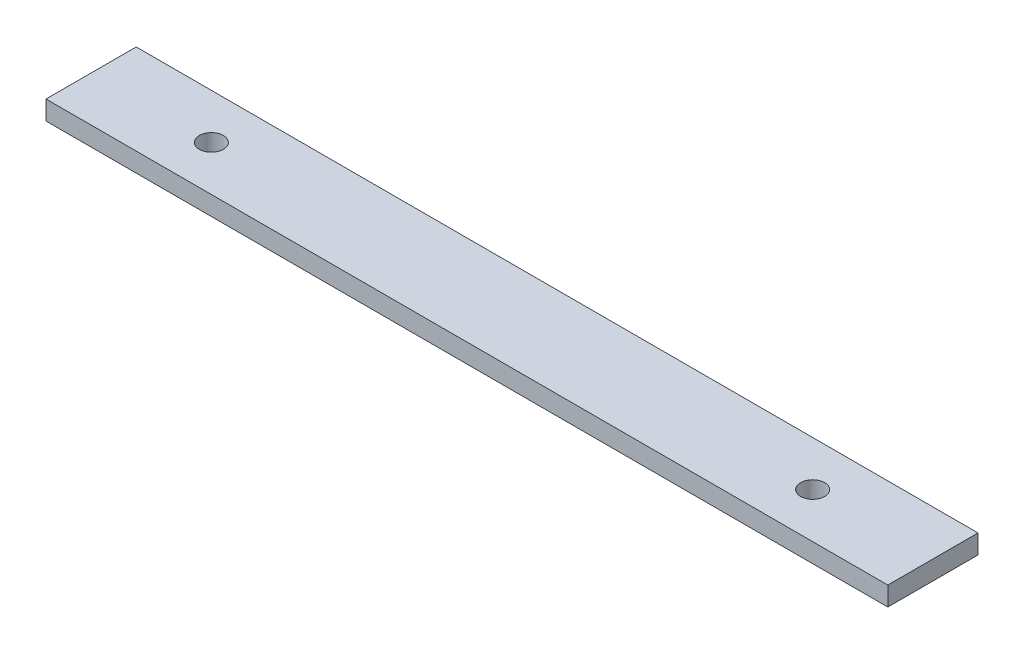
from build123d import *

# Parameters (mm, degrees)
SKETCH1_W           = 140
SKETCH1_H           = 15
SKETCH1_R           = 2
BOSS_EXTRUDE1_DEPTH = 3.175


with BuildPart() as part:
    # Sketch1 → Boss-Extrude1 (new body)
    with BuildSketch(Plane(origin=(0, 0, 0), x_dir=(1, 0, 0), z_dir=(0, 1, 0))):
        Rectangle(SKETCH1_W, SKETCH1_H)
        with Locations((-50, 0)):
            Circle(SKETCH1_R, mode=Mode.SUBTRACT)
        with Locations((50, 0)):
            Circle(SKETCH1_R, mode=Mode.SUBTRACT)
    extrude(amount=BOSS_EXTRUDE1_DEPTH)


solid = part.part
